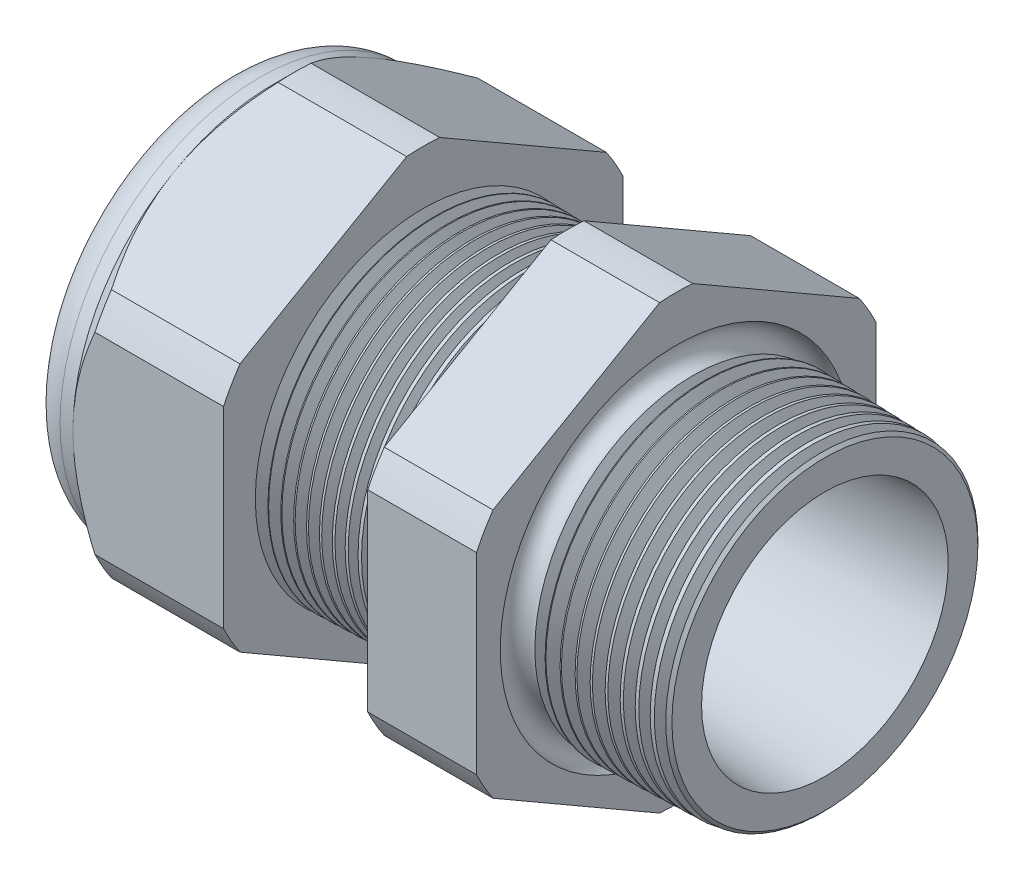
from build123d import *

# Parameters (mm, degrees)
SKETCH12_OUTSIDE_W = 65.04
SKETCH12_OUTSIDE_H = 65.04
CUT_EXTRUDE2_DEPTH = 34.014
FILLET4_R          = 2.032
SKETCH19_OUTSIDE_W = 39.986
SKETCH19_OUTSIDE_H = 42.612
SKETCH19_OUTSIDE_R = 11.938
CUT_EXTRUDE3_DEPTH = 1.999996
CUT_EXTRUDE3_DRAFT = -45
CHAMFER1_SIZE      = 0.260919487
CHAMFER1_SIZE2     = 0.254
SKETCH21_R         = 5.969
PLUG_DEPTH         = 6.35
SKETCH22_R         = 5.715
CUT_EXTRUDE4_DEPTH = 0.508
SKETCH27_R         = 1.905
PLUGHOLES_DEPTH    = 36.306
CIRPATTERN1_COUNT  = 2
LPATTERN1_COUNT    = 11
LPATTERN1_PITCH    = 0.762
LPATTERN2_COUNT    = 10
LPATTERN2_PITCH    = 0.889
SKETCH32_R         = 0.889


with BuildPart() as part:
    # Sketch10 → Revolve2 (revolve)
    with BuildSketch(Plane.XY, mode=Mode.PRIVATE) as revolve2_sk:
        Polygon((-34.798, 5.969), (-22.998, 5.969), (1.016, 7.372171279), (1.016, 9.404171279), (-7.874, 9.636964122), (-7.874, 23.876), (-14.374, 23.876), (-14.374, 9.807172612), (-22.998, 10.033), (-22.998, 23.876), (-31.998, 23.876), (-31.998, 11.938), (-34.798, 11.938), align=None)
    revolve(revolve2_sk.sketch.rotate(Axis((0, 0, 0), (-1, 0, 0)), 90), axis=Axis((0, 0, 0), (-1, 0, 0)))  # turned: the seam where the file's is

    # Sketch12 outside → Cut-Extrude2 (cut, through all)
    with BuildSketch(Plane.ZY.offset(31.998)):
        Rectangle(SKETCH12_OUTSIDE_W, SKETCH12_OUTSIDE_H)
        with BuildLine():
            Line((-0.98819228, 13.214281948), (-10.94980772, 7.462940592))
            ThreePointArc((-10.94980772, 7.462940592), (-11.47585851, 6.62559), (-11.938, 5.751341356))
            Line((-11.938, 5.751341356), (-11.938, -5.751341356))
            ThreePointArc((-11.938, -5.751341356), (-11.47585851, -6.62559), (-10.94980772, -7.462940592))
            Line((-10.94980772, -7.462940592), (-0.98819228, -13.214281948))
            ThreePointArc((-0.98819228, -13.214281948), (0, -13.25118), (0.98819228, -13.214281948))
            Line((0.98819228, -13.214281948), (10.94980772, -7.462940592))
            ThreePointArc((10.94980772, -7.462940592), (11.47585851, -6.62559), (11.938, -5.751341356))
            Line((11.938, -5.751341356), (11.938, 5.751341356))
            ThreePointArc((11.938, 5.751341356), (11.47585851, 6.62559), (10.94980772, 7.462940592))
            Line((10.94980772, 7.462940592), (0.98819228, 13.214281948))
            ThreePointArc((0.98819228, 13.214281948), (0, 13.25118), (-0.98819228, 13.214281948))
        make_face(mode=Mode.SUBTRACT)
    extrude(amount=-CUT_EXTRUDE2_DEPTH, mode=Mode.SUBTRACT)

    # Fillet4
    fillet4_edges = [part.edges().sort_by_distance(p)[0] for p in [
        (-34.798, 0, 11.938),
    ]]
    fillet(fillet4_edges, radius=FILLET4_R)


with BuildPart() as cut_extrude3_tool:
    # Sketch19 outside → Cut-Extrude3 (with draft: the straight prism first)
    with BuildSketch(Plane.ZY.offset(31.998)):
        Rectangle(SKETCH19_OUTSIDE_W, SKETCH19_OUTSIDE_H)
        Circle(SKETCH19_OUTSIDE_R, mode=Mode.SUBTRACT)
    extrude(amount=-CUT_EXTRUDE3_DEPTH)
    # Cut-Extrude3: the draft: its side faces are tilted about the plane it starts from
    cut_extrude3_sides = [cut_extrude3_tool.faces().sort_by_distance(p)[0] for p in [
        (-30.998002, -21.306, 0),
        (-30.998002, 0, 19.993),
        (-30.998002, 21.306, 0),
        (-30.998002, 0, -19.993),
        (-30.998002, 0, -11.938),
    ]]
    draft(cut_extrude3_sides, Plane.ZY.offset(31.998), CUT_EXTRUDE3_DRAFT)


with BuildPart() as part_1:
    add(part.part)

    # Cut-Extrude3: cut by cut_extrude3_tool
    add(cut_extrude3_tool.part, mode=Mode.SUBTRACT)

    # Chamfer1
    chamfer1_edges = [part_1.edges().sort_by_distance(p)[0] for p in [
        (1.016, 0, 9.404171279),
    ]]
    chamfer1_side = [part_1.faces().sort_by_distance(p)[0] for p in [
        (1.016, 0, 7.638161411),
    ]]
    chamfer(chamfer1_edges, length=CHAMFER1_SIZE, length2=CHAMFER1_SIZE2, reference=chamfer1_side[0])

    # Sketch29 → Cut-Revolve1 (revolve, cut)
    with BuildSketch(Plane.XY, mode=Mode.PRIVATE) as cut_revolve1_sk:
        Polygon((-22.998, 10.033), (-22.265016419, 10.013806149), (-22.648130572, 9.388620673), align=None)
    cut_revolve1 = revolve(cut_revolve1_sk.sketch.rotate(Axis((0, 0, 0), (-1, 0, 0)), 90), axis=Axis((0, 0, 0), (-1, 0, 0)), mode=Mode.SUBTRACT)  # turned: the seam where the file's is

    # LPattern1: Cut-Revolve1 ×11
    with Locations(*[(i * LPATTERN1_PITCH, 0, 0) for i in range(1, LPATTERN1_COUNT)]):
        add(cut_revolve1, mode=Mode.SUBTRACT)

    # Sketch30 → Cut-Revolve2 (revolve, cut)
    with BuildSketch(Plane.XY, mode=Mode.PRIVATE) as cut_revolve2_sk:
        Polygon((-7.874, 9.636964122), (-6.994419703, 9.613931502), (-7.454156686, 8.86370893), align=None)
    cut_revolve2 = revolve(cut_revolve2_sk.sketch.rotate(Axis((0, 0, 0), (-1, 0, 0)), 270), axis=Axis((0, 0, 0), (-1, 0, 0)), mode=Mode.SUBTRACT)  # turned: the seam where the file's is

    # LPattern2: Cut-Revolve2 ×10
    with Locations(*[(i * LPATTERN2_PITCH, 0, 0) for i in range(1, LPATTERN2_COUNT)]):
        add(cut_revolve2, mode=Mode.SUBTRACT)

    # Sketch32 → Cut-Revolve3 (revolve, cut)
    with BuildSketch(Plane.XY, mode=Mode.PRIVATE) as cut_revolve3_sk:
        with Locations((-7.747, 9.636964122)):
            Circle(SKETCH32_R)
    revolve(cut_revolve3_sk.sketch.rotate(Axis((0, 0, 0), (-1, 0, 0)), 270), axis=Axis((0, 0, 0), (-1, 0, 0)), mode=Mode.SUBTRACT)  # turned: the seam where the file's is


with BuildPart() as body_2:
    # Sketch21 → plug (new body)
    with BuildSketch(Plane.ZY.offset(34.798)):
        Circle(SKETCH21_R)
    extrude(amount=-PLUG_DEPTH)

    # Sketch22 → Cut-Extrude4 (cut)
    with BuildSketch(Plane.ZY.offset(34.798)):
        Circle(SKETCH22_R)
    extrude(amount=-CUT_EXTRUDE4_DEPTH, mode=Mode.SUBTRACT)

    # Sketch27 → plugholes (cut, through all)
    with BuildSketch(Plane.ZY.offset(34.29)):
        with Locations((-3.80238, 0)):
            Circle(SKETCH27_R)
    plugholes = extrude(amount=-PLUGHOLES_DEPTH, mode=Mode.SUBTRACT)

    # CirPattern1: plugholes ×2 about axis
    cirpattern1_axis = Axis((0, 0, 0), (1, 0, 0))
    for i in range(1, CIRPATTERN1_COUNT):
        add(plugholes.rotate(cirpattern1_axis, i * 360 / CIRPATTERN1_COUNT), mode=Mode.SUBTRACT)


solid = Compound([part_1.part, body_2.part])
